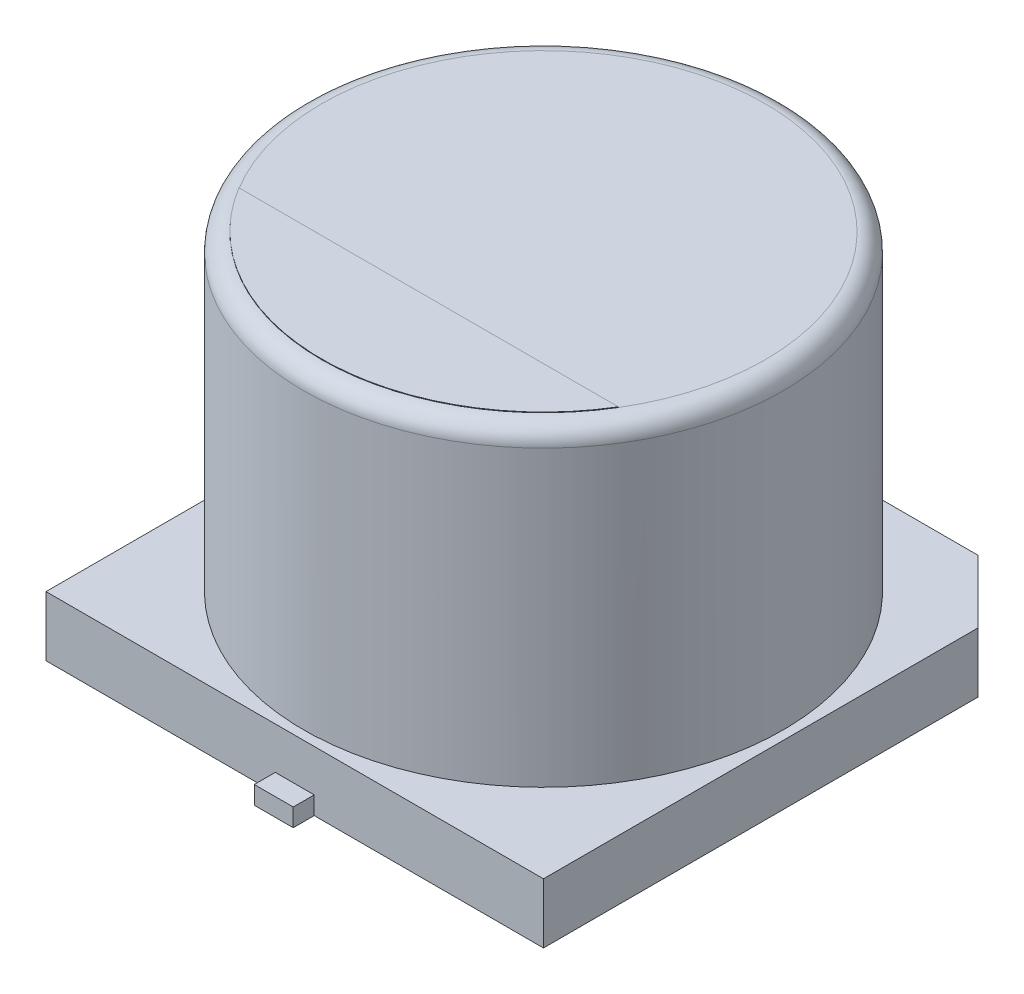
from build123d import *

# Parameters (mm, degrees)
BOSS_EXTRUDE1_DEPTH = 1
SKETCH3_R           = 4
BOSS_EXTRUDE2_DEPTH = 6.2
FILLET1_R           = 0.3
SKETCH4_W           = 0.65
SKETCH4_H           = 3.4
BOSS_EXTRUDE3_DEPTH = 0.3
BOSS_EXTRUDE4_DEPTH = 0.01


with BuildPart() as part:
    # Sketch2 → Boss-Extrude1 (new body)
    with BuildSketch(Plane(origin=(0, 0, 0), x_dir=(1, 0, 0), z_dir=(0, 1, 0))):
        Polygon((4.15, -4.15), (-4.15, -4.15), (-4.15, 3.1), (-3.1, 4.15), (3.1, 4.15), (4.15, 3.1), align=None)
    extrude(amount=BOSS_EXTRUDE1_DEPTH)

    # Sketch3 → Boss-Extrude2 (add)
    with BuildSketch(Plane(origin=(0, 0, 0), x_dir=(1, 0, 0), z_dir=(0, 1, 0))):
        Circle(SKETCH3_R)
    extrude(amount=BOSS_EXTRUDE2_DEPTH)

    # Fillet1
    fillet1_edges = [part.edges().sort_by_distance(p)[0] for p in [
        (-4, 6.2, 0),
    ]]
    fillet(fillet1_edges, radius=FILLET1_R)

    # Sketch4 → Boss-Extrude3 (add)
    with BuildSketch(Plane(origin=(0, 0, 0), x_dir=(1, 0, 0), z_dir=(0, 1, 0))):
        with Locations((0, 2.8)):
            Rectangle(SKETCH4_W, SKETCH4_H)
        with Locations((0, -2.8)):
            Rectangle(SKETCH4_W, SKETCH4_H)
    extrude(amount=BOSS_EXTRUDE3_DEPTH)

    # Sketch5 → Boss-Extrude4 (add)
    with BuildSketch(Plane(origin=(0, 6.2, 0), x_dir=(1, 0, 0), z_dir=(0, 1, 0))):
        with BuildLine():
            Line((-3.165033817, -1.916392689), (3.165033817, -1.916392689))
            ThreePointArc((3.165033817, -1.916392689), (0, -3.7), (-3.165033817, -1.916392689))
        make_face()
    extrude(amount=BOSS_EXTRUDE4_DEPTH)


solid = part.part
